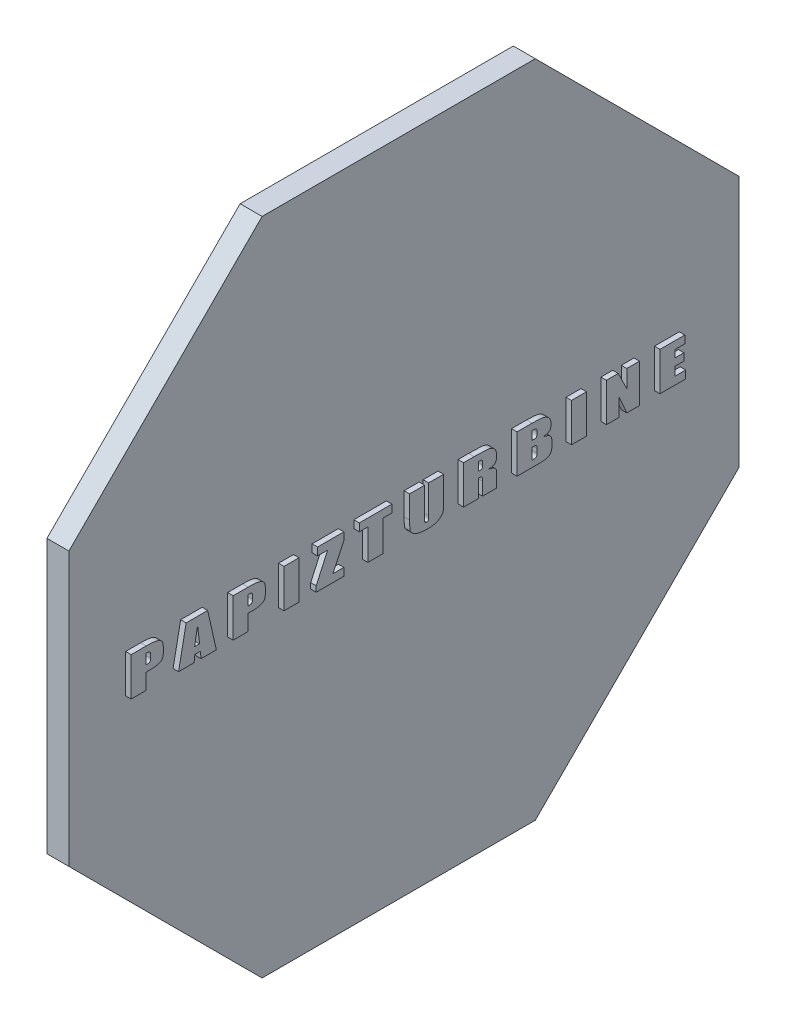
from build123d import *

# Parameters (mm, degrees)
BOSS_EXTRUDE1_DEPTH = 2
SKETCH2_R           = 28.115
BOSS_EXTRUDE2_DEPTH = 0.5
SKETCH3_W           = 1.35882353
SKETCH3_H           = 3.5
SKETCH3_W_2         = 1.358823529
BOSS_EXTRUDE3_DEPTH = 0.5


with BuildPart() as part:
    # Sketch1 → Boss-Extrude1 (new body)
    with BuildSketch(Plane(origin=(0, 0, 0), x_dir=(0, 0, -1), z_dir=(1, 0, 0))):
        Polygon((-30, 6.213203436), (-12.426406871, 23.786796564), (12.426406871, 23.786796564), (30.963363929, 5.249839506), (30.963363929, -17.676246377), (12.426406871, -36.213203436), (-12.426406871, -36.213203436), (-30, -18.639610307), align=None)
    extrude(amount=BOSS_EXTRUDE1_DEPTH)

    # Sketch2 → Boss-Extrude2 (add)
    with BuildSketch(Plane.ZY):
        with Locations((0, -6.213203436)):
            Circle(SKETCH2_R)
    extrude(amount=BOSS_EXTRUDE2_DEPTH)

    # Sketch3 → Boss-Extrude3 (add)
    with BuildSketch(Plane(origin=(2, 0, 0), x_dir=(0, 0, -1), z_dir=(1, 0, 0))):
        with BuildLine():
            Line((-24.836470588, -4.281409822), (-23.469926471, -4.281409822))
            add(Edge.make_bspline(
                [(-23.469926471, -4.281409822), (-23.425101442, -4.281405393), (-23.338011949, -4.281396789), (-23.211476018, -4.284987067), (-23.092873966, -4.289464045), (-22.982137851, -4.294805407), (-22.879383931, -4.303210882), (-22.784814533, -4.313601578), (-22.698266469, -4.324838982), (-22.619369548, -4.338583734), (-22.546378684, -4.353432135), (-22.478479043, -4.369905831), (-22.415417836, -4.388581779), (-22.357116435, -4.408765293), (-22.303126878, -4.429504237), (-22.253920983, -4.45279967), (-22.209493707, -4.477885134), (-22.157208479, -4.512451241), (-22.099608589, -4.559239418), (-22.042698667, -4.623017809), (-21.996269664, -4.691761253), (-21.96936758, -4.755374502), (-21.953320666, -4.810375007), (-21.942472988, -4.856996042), (-21.932611986, -4.908865982), (-21.92608072, -4.966318462), (-21.920246186, -5.028735747), (-21.915694745, -5.096304272), (-21.913139224, -5.16925708), (-21.913008844, -5.219673694), (-21.912941176, -5.245839969)],
                knots=[0, 0, 0, 0, 0.000134468, 0.000261256, 0.000379724, 0.000490537, 0.000593817, 0.000688953, 0.00077594, 0.000855587, 0.00092915, 0.00099937, 0.001065124, 0.001126367, 0.001184432, 0.001238538, 0.001289532, 0.001337355, 0.001426488, 0.001511229, 0.001592956, 0.001674226, 0.001717179, 0.001764776, 0.001817776, 0.001875473, 0.001938149, 0.002005854, 0.002078602, 0.002157097, 0.002157097, 0.002157097, 0.002157097], degree=3))
            Line((-21.912941176, -5.245839969), (-21.912941176, -5.546299528))
            add(Edge.make_bspline(
                [(-21.912941176, -5.546299528), (-21.91302739, -5.572906859), (-21.913193743, -5.624246763), (-21.918985118, -5.69845728), (-21.92577172, -5.76715505), (-21.938112938, -5.830109998), (-21.951220936, -5.887932251), (-21.969926294, -5.93967271), (-21.989849404, -5.986561937), (-22.015012001, -6.027750729), (-22.04395761, -6.065457537), (-22.078190443, -6.100119104), (-22.117916574, -6.132276841), (-22.16243981, -6.162836571), (-22.212960106, -6.190139942), (-22.268417051, -6.215856149), (-22.329106444, -6.239818328), (-22.39536495, -6.260853617), (-22.466991537, -6.27919021), (-22.543667057, -6.2964037), (-22.626078053, -6.309166585), (-22.713506187, -6.321283532), (-22.806312271, -6.329015634), (-22.904099073, -6.335693972), (-23.007304213, -6.339527169), (-23.077889228, -6.339993752), (-23.114136029, -6.340233351)],
                knots=[0, 0, 0, 0, 7.979e-05, 0.000153958, 0.000223231, 0.000286705, 0.000346314, 0.000400846, 0.000451539, 0.000498874, 0.000545202, 0.000593883, 0.000644629, 0.000698342, 0.000755647, 0.00081667, 0.000881664, 0.000951251, 0.001025063, 0.001103432, 0.001186886, 0.001275149, 0.001368173, 0.001466178, 0.001569192, 0.001677931, 0.001677931, 0.001677931, 0.001677931], degree=3))
            Line((-23.114136029, -6.340233351), (-23.477647059, -6.340233351))
            Line((-23.477647059, -6.340233351), (-23.477647059, -7.781409822))
            Line((-23.477647059, -7.781409822), (-24.836470588, -7.781409822))
            Line((-24.836470588, -7.781409822), (-24.836470588, -4.281409822))
        make_face()
        with BuildLine():
            Line((-23.477647059, -4.85788041), (-23.477647059, -5.761832616))
            add(Edge.make_bspline(
                [(-23.477647059, -5.761832616), (-23.460491144, -5.762309262), (-23.428755679, -5.763190974), (-23.397010488, -5.763582769), (-23.382426471, -5.763762763)],
                knots=[0, 0, 0, 0, 5.1487e-05, 9.5241e-05, 9.5241e-05, 9.5241e-05, 9.5241e-05], degree=3))
            add(Edge.make_bspline(
                [(-23.382426471, -5.763762763), (-23.35494615, -5.763112615), (-23.304196772, -5.761911953), (-23.234459263, -5.751248359), (-23.178586037, -5.731373566), (-23.140367871, -5.708302022), (-23.11837518, -5.68320143), (-23.10427052, -5.661022586), (-23.091638793, -5.634826623), (-23.082767713, -5.604065594), (-23.074550784, -5.569362909), (-23.070002748, -5.530307722), (-23.06665438, -5.487166716), (-23.066146745, -5.457091997), (-23.065882353, -5.441428204)],
                knots=[0, 0, 0, 0, 8.2443e-05, 0.000152253, 0.000210464, 0.000259715, 0.000283865, 0.00030992, 0.000338411, 0.000370766, 0.000405729, 0.000445311, 0.000488538, 0.000535522, 0.000535522, 0.000535522, 0.000535522], degree=3))
            Line((-23.065882353, -5.441428204), (-23.065882353, -5.149332616))
            add(Edge.make_bspline(
                [(-23.065882353, -5.149332616), (-23.066075228, -5.134735201), (-23.066441884, -5.106985541), (-23.070628434, -5.067495747), (-23.075898477, -5.031588385), (-23.084925008, -4.999986474), (-23.095793146, -4.971819213), (-23.110116254, -4.948256891), (-23.125969469, -4.927663129), (-23.14576161, -4.911671626), (-23.169187256, -4.898358651), (-23.197808987, -4.887956844), (-23.231278123, -4.878206105), (-23.270257409, -4.87061682), (-23.314566818, -4.865200579), (-23.36411428, -4.860563774), (-23.419073584, -4.85807302), (-23.457485494, -4.857946708), (-23.477647059, -4.85788041)],
                knots=[0, 0, 0, 0, 4.3769e-05, 8.3205e-05, 0.000119061, 0.000152468, 0.000181619, 0.000209315, 0.000234937, 0.000259156, 0.000285092, 0.00031544, 0.00035026, 0.000389627, 0.000434397, 0.000484141, 0.000538889, 0.000599371, 0.000599371, 0.000599371, 0.000599371], degree=3))
        make_face(mode=Mode.SUBTRACT)
        Polygon((-17.879705882, -4.281409822), (-17.087058824, -7.781409822), (-18.476764706, -7.781409822), (-18.548180147, -7.163762763), (-19.043584559, -7.163762763), (-19.115, -7.781409822), (-20.525294118, -7.781409822), (-19.835588235, -4.281409822), align=None)
        with BuildLine():
            add(Edge.make_bspline(
                [(-18.609301471, -6.546115704), (-18.615721023, -6.4929277), (-18.628897965, -6.383752608), (-18.64947351, -6.215613594), (-18.671709793, -6.038539558), (-18.693482531, -5.852457751), (-18.718918456, -5.657713412), (-18.742464881, -5.453786322), (-18.769400985, -5.241161877), (-18.786943241, -5.096369169), (-18.795882353, -5.022586292)],
                knots=[0, 0, 0, 0, 0.000160722, 0.000329902, 0.00050818, 0.000696114, 0.000891948, 0.00109736, 0.001311947, 0.001534914, 0.001534914, 0.001534914, 0.001534914], degree=3))
            add(Edge.make_bspline(
                [(-18.795882353, -5.022586292), (-18.810596459, -5.106669742), (-18.838979655, -5.268864927), (-18.881360925, -5.503095295), (-18.918852638, -5.720073536), (-18.954392164, -5.919242747), (-18.986680329, -6.100869863), (-19.015325743, -6.265025068), (-19.042069926, -6.411360595), (-19.058012876, -6.503212995), (-19.065459559, -6.546115704)],
                knots=[0, 0, 0, 0, 0.000256083, 0.000493979, 0.000714097, 0.00091666, 0.001100924, 0.001267521, 0.001416565, 0.001547197, 0.001547197, 0.001547197, 0.001547197], degree=3))
            Line((-19.065459559, -6.546115704), (-18.609301471, -6.546115704))
        make_face(mode=Mode.SUBTRACT)
        with BuildLine():
            Line((-15.555294118, -4.281409822), (-14.18875, -4.281409822))
            add(Edge.make_bspline(
                [(-14.18875, -4.281409822), (-14.143924972, -4.281405393), (-14.056835478, -4.281396789), (-13.930299548, -4.284987067), (-13.811697495, -4.289464045), (-13.700961381, -4.294805407), (-13.59820746, -4.303210882), (-13.503638062, -4.313601578), (-13.417089999, -4.324838982), (-13.338193077, -4.338583734), (-13.265202213, -4.353432135), (-13.197302572, -4.369905831), (-13.134241365, -4.388581779), (-13.075939964, -4.408765293), (-13.021950407, -4.429504237), (-12.972744512, -4.45279967), (-12.928317237, -4.477885134), (-12.876032008, -4.512451241), (-12.818432118, -4.559239418), (-12.761522196, -4.623017809), (-12.715093193, -4.691761253), (-12.68819111, -4.755374502), (-12.672144195, -4.810375007), (-12.661296517, -4.856996042), (-12.651435515, -4.908865982), (-12.644904249, -4.966318462), (-12.639069715, -5.028735747), (-12.634518274, -5.096304272), (-12.631962754, -5.16925708), (-12.631832373, -5.219673694), (-12.631764706, -5.245839969)],
                knots=[0, 0, 0, 0, 0.000134468, 0.000261256, 0.000379724, 0.000490537, 0.000593817, 0.000688953, 0.00077594, 0.000855587, 0.00092915, 0.00099937, 0.001065124, 0.001126367, 0.001184432, 0.001238538, 0.001289532, 0.001337355, 0.001426488, 0.001511229, 0.001592956, 0.001674226, 0.001717179, 0.001764776, 0.001817776, 0.001875473, 0.001938149, 0.002005854, 0.002078602, 0.002157097, 0.002157097, 0.002157097, 0.002157097], degree=3))
            Line((-12.631764706, -5.245839969), (-12.631764706, -5.546299528))
            add(Edge.make_bspline(
                [(-12.631764706, -5.546299528), (-12.63185092, -5.572906859), (-12.632017272, -5.624246763), (-12.637808647, -5.69845728), (-12.64459525, -5.76715505), (-12.656936467, -5.830109998), (-12.670044466, -5.887932251), (-12.688749823, -5.93967271), (-12.708672933, -5.986561937), (-12.73383553, -6.027750729), (-12.762781139, -6.065457537), (-12.797013972, -6.100119104), (-12.836740104, -6.132276841), (-12.881263339, -6.162836571), (-12.931783636, -6.190139942), (-12.987240581, -6.215856149), (-13.047929974, -6.239818328), (-13.114188479, -6.260853617), (-13.185815066, -6.27919021), (-13.262490587, -6.2964037), (-13.344901583, -6.309166585), (-13.432329717, -6.321283532), (-13.525135801, -6.329015634), (-13.622922603, -6.335693972), (-13.726127743, -6.339527169), (-13.796712758, -6.339993752), (-13.832959559, -6.340233351)],
                knots=[0, 0, 0, 0, 7.979e-05, 0.000153958, 0.000223231, 0.000286705, 0.000346314, 0.000400846, 0.000451539, 0.000498874, 0.000545202, 0.000593883, 0.000644629, 0.000698342, 0.000755647, 0.00081667, 0.000881664, 0.000951251, 0.001025063, 0.001103432, 0.001186886, 0.001275149, 0.001368173, 0.001466178, 0.001569192, 0.001677931, 0.001677931, 0.001677931, 0.001677931], degree=3))
            Line((-13.832959559, -6.340233351), (-14.196470588, -6.340233351))
            Line((-14.196470588, -6.340233351), (-14.196470588, -7.781409822))
            Line((-14.196470588, -7.781409822), (-15.555294118, -7.781409822))
            Line((-15.555294118, -7.781409822), (-15.555294118, -4.281409822))
        make_face()
        with BuildLine():
            Line((-14.196470588, -4.85788041), (-14.196470588, -5.761832616))
            add(Edge.make_bspline(
                [(-14.196470588, -5.761832616), (-14.179314673, -5.762309262), (-14.147579208, -5.763190974), (-14.115834018, -5.763582769), (-14.10125, -5.763762763)],
                knots=[0, 0, 0, 0, 5.1487e-05, 9.5241e-05, 9.5241e-05, 9.5241e-05, 9.5241e-05], degree=3))
            add(Edge.make_bspline(
                [(-14.10125, -5.763762763), (-14.073769679, -5.763112615), (-14.023020302, -5.761911953), (-13.953282792, -5.751248359), (-13.897409567, -5.731373566), (-13.859191401, -5.708302022), (-13.837198709, -5.68320143), (-13.82309405, -5.661022586), (-13.810462322, -5.634826623), (-13.801591243, -5.604065594), (-13.793374314, -5.569362909), (-13.788826278, -5.530307722), (-13.78547791, -5.487166716), (-13.784970274, -5.457091997), (-13.784705882, -5.441428204)],
                knots=[0, 0, 0, 0, 8.2443e-05, 0.000152253, 0.000210464, 0.000259715, 0.000283865, 0.00030992, 0.000338411, 0.000370766, 0.000405729, 0.000445311, 0.000488538, 0.000535522, 0.000535522, 0.000535522, 0.000535522], degree=3))
            Line((-13.784705882, -5.441428204), (-13.784705882, -5.149332616))
            add(Edge.make_bspline(
                [(-13.784705882, -5.149332616), (-13.784898758, -5.134735201), (-13.785265413, -5.106985541), (-13.789451964, -5.067495747), (-13.794722006, -5.031588385), (-13.803748538, -4.999986474), (-13.814616675, -4.971819213), (-13.828939784, -4.948256891), (-13.844792998, -4.927663129), (-13.864585139, -4.911671626), (-13.888010785, -4.898358651), (-13.916632516, -4.887956844), (-13.950101652, -4.878206105), (-13.989080939, -4.87061682), (-14.033390347, -4.865200579), (-14.08293781, -4.860563774), (-14.137897113, -4.85807302), (-14.176309023, -4.857946708), (-14.196470588, -4.85788041)],
                knots=[0, 0, 0, 0, 4.3769e-05, 8.3205e-05, 0.000119061, 0.000152468, 0.000181619, 0.000209315, 0.000234937, 0.000259156, 0.000285092, 0.00031544, 0.00035026, 0.000389627, 0.000434397, 0.000484141, 0.000538889, 0.000599371, 0.000599371, 0.000599371, 0.000599371], degree=3))
        make_face(mode=Mode.SUBTRACT)
        with Locations((-10.255882353, -6.031409822)):
            Rectangle(SKETCH3_W, SKETCH3_H)
        Polygon((-5.491764706, -4.281409822), (-5.491764706, -4.981409822), (-6.490294118, -7.081409822), (-5.491764706, -7.081409822), (-5.491764706, -7.781409822), (-8.003529412, -7.781409822), (-8.003529412, -7.273781145), (-6.963180147, -4.981409822), (-7.88, -4.981409822), (-7.88, -4.281409822), align=None)
        Polygon((-1.118823529, -4.281409822), (-1.118823529, -4.981409822), (-1.942352941, -4.981409822), (-1.942352941, -7.781409822), (-3.301176471, -7.781409822), (-3.301176471, -4.981409822), (-4.083529412, -4.981409822), (-4.083529412, -4.281409822), align=None)
        with BuildLine():
            Line((3.583529412, -4.281409822), (3.583529412, -6.626538498))
            add(Edge.make_bspline(
                [(3.583529412, -6.626538498), (3.583444896, -6.658495339), (3.583282655, -6.719841698), (3.580979182, -6.808190179), (3.579066078, -6.889315597), (3.574033598, -6.963050416), (3.569600084, -7.029442718), (3.562119431, -7.088154793), (3.554667581, -7.139718162), (3.543207438, -7.199851003), (3.517069697, -7.271107603), (3.469000461, -7.35472259), (3.400442606, -7.437730804), (3.316579685, -7.522378625), (3.214714995, -7.601683323), (3.096326103, -7.67103906), (2.963644254, -7.731189945), (2.815741938, -7.779513128), (2.653543522, -7.816991731), (2.477703032, -7.844581218), (2.287831123, -7.860354737), (2.156751246, -7.862600946), (2.088952206, -7.863762763)],
                knots=[0, 0, 0, 0, 9.5866e-05, 0.000184031, 0.000265138, 0.000339264, 0.000405732, 0.000464706, 0.000516752, 0.00056205, 0.000648131, 0.000742936, 0.000850047, 0.000970151, 0.00109988, 0.00123604, 0.001380871, 0.001536107, 0.001701998, 0.001879807, 0.002069644, 0.002273035, 0.002273035, 0.002273035, 0.002273035], degree=3))
            add(Edge.make_bspline(
                [(2.088952206, -7.863762763), (2.013852223, -7.862569659), (1.867680694, -7.860247452), (1.655190061, -7.84109391), (1.456182525, -7.808118444), (1.299728224, -7.770856131), (1.183127985, -7.734246472), (1.102445904, -7.705213391), (1.027315976, -7.674743006), (0.958072913, -7.641607067), (0.894012612, -7.60703853), (0.835825455, -7.56994187), (0.783120175, -7.531060615), (0.721713962, -7.478132918), (0.657055002, -7.408420739), (0.594397993, -7.321028516), (0.550195457, -7.230607891), (0.528519052, -7.150557748), (0.518852143, -7.079848527), (0.512592358, -7.014374646), (0.507718995, -6.936041084), (0.503314631, -6.845098697), (0.499358181, -6.741300751), (0.496902832, -6.624833724), (0.495801781, -6.495505104), (0.4954686, -6.405000663), (0.495294118, -6.357604675)],
                knots=[0, 0, 0, 0, 0.000225276, 0.000438467, 0.000639327, 0.000830016, 0.000920365, 0.001005841, 0.001087205, 0.001163467, 0.001236021, 0.001305449, 0.001370304, 0.001432342, 0.001548424, 0.001654631, 0.001753908, 0.001848652, 0.001901971, 0.00196791, 0.00204593, 0.002137401, 0.002241057, 0.002357538, 0.002486864, 0.002629053, 0.002629053, 0.002629053, 0.002629053], degree=3))
            Line((0.495294118, -6.357604675), (0.495294118, -4.281409822))
            Line((0.495294118, -4.281409822), (1.854117647, -4.281409822))
            Line((1.854117647, -4.281409822), (1.854117647, -6.927641439))
            add(Edge.make_bspline(
                [(1.854117647, -6.927641439), (1.854314438, -6.946084027), (1.854687474, -6.981043617), (1.85549355, -7.031067876), (1.858958924, -7.075667569), (1.862833915, -7.115347124), (1.866942083, -7.149785633), (1.872678874, -7.179054811), (1.879528475, -7.203082043), (1.890371991, -7.228074986), (1.910160784, -7.252985974), (1.94321731, -7.27367556), (1.98478133, -7.285669077), (2.015307119, -7.28672528), (2.031691176, -7.287292175)],
                knots=[0, 0, 0, 0, 5.5335e-05, 0.000104892, 0.000150043, 0.000189479, 0.000224512, 0.000254038, 0.000278873, 0.00029932, 0.000335493, 0.000372256, 0.000414592, 0.000463641, 0.000463641, 0.000463641, 0.000463641], degree=3))
            add(Edge.make_bspline(
                [(2.031691176, -7.287292175), (2.050446266, -7.286604599), (2.084905344, -7.285341304), (2.131351816, -7.272156168), (2.167476784, -7.249569296), (2.187979714, -7.221922144), (2.198817803, -7.194283566), (2.205318297, -7.167149125), (2.21209384, -7.134408633), (2.21599329, -7.095388532), (2.219838648, -7.050570783), (2.223351424, -6.999750119), (2.22412946, -6.942869368), (2.224506989, -6.902977525), (2.224705882, -6.881961292)],
                knots=[0, 0, 0, 0, 5.6155e-05, 0.000103175, 0.000143148, 0.00018175, 0.000203973, 0.000231906, 0.000265344, 0.000304208, 0.00034941, 0.000400339, 0.000456971, 0.000520026, 0.000520026, 0.000520026, 0.000520026], degree=3))
            Line((2.224705882, -6.881961292), (2.224705882, -4.281409822))
            Line((2.224705882, -4.281409822), (3.583529412, -4.281409822))
        make_face()
        with BuildLine():
            Line((5.403529412, -4.281409822), (6.356378676, -4.281409822))
            add(Edge.make_bspline(
                [(6.356378676, -4.281409822), (6.432513175, -4.281461402), (6.578567719, -4.281560353), (6.787887235, -4.284279574), (6.978119287, -4.288103724), (7.148864545, -4.292864007), (7.300496123, -4.300028844), (7.432850026, -4.308214294), (7.546182803, -4.317457882), (7.642863999, -4.328916566), (7.727970102, -4.34403796), (7.806637236, -4.363348595), (7.881596189, -4.387018374), (7.95268233, -4.415940231), (8.019417773, -4.450402836), (8.083046745, -4.487966439), (8.14186338, -4.531800339), (8.197368108, -4.579740027), (8.248482262, -4.633811691), (8.291403147, -4.696442713), (8.32855889, -4.765750364), (8.357861078, -4.843078211), (8.380874753, -4.927570308), (8.397354625, -5.019495189), (8.407916597, -5.118847163), (8.408901866, -5.187692532), (8.409411765, -5.223321586)],
                knots=[0, 0, 0, 0, 0.000228402, 0.00043816, 0.000627997, 0.000799214, 0.000950575, 0.001083375, 0.001197021, 0.001291666, 0.001375338, 0.001456169, 0.001534506, 0.001610971, 0.00168607, 0.001759667, 0.001832372, 0.001905788, 0.001979539, 0.002054858, 0.002132859, 0.002214943, 0.00230235, 0.002395229, 0.002494844, 0.002601693, 0.002601693, 0.002601693, 0.002601693], degree=3))
            add(Edge.make_bspline(
                [(8.409411765, -5.223321586), (8.408922506, -5.25550616), (8.407985112, -5.317170098), (8.40079384, -5.405676555), (8.389804423, -5.486000314), (8.37318376, -5.558225995), (8.351314626, -5.621924393), (8.325733937, -5.678202531), (8.295141827, -5.726469121), (8.257680996, -5.766330701), (8.213466073, -5.800162504), (8.161116833, -5.82936307), (8.099755332, -5.855111997), (8.029277045, -5.877329455), (7.949538563, -5.89653938), (7.860487306, -5.91147669), (7.762636881, -5.923965684), (7.69421926, -5.928618695), (7.658584559, -5.931042175)],
                knots=[0, 0, 0, 0, 9.6542e-05, 0.000184969, 0.000266221, 0.000339569, 0.000406916, 0.000467939, 0.000524688, 0.000577492, 0.000631156, 0.000691087, 0.000756813, 0.000830469, 0.00091255, 0.001002669, 0.001101224, 0.001208353, 0.001208353, 0.001208353, 0.001208353], degree=3))
            add(Edge.make_bspline(
                [(7.658584559, -5.931042175), (7.69099384, -5.936910654), (7.753161842, -5.948167665), (7.842151713, -5.966520821), (7.922757002, -5.986855176), (7.994667532, -6.00966), (8.058902787, -6.032188548), (8.114382659, -6.057610468), (8.162335352, -6.083188705), (8.212373753, -6.119912313), (8.26344277, -6.165033474), (8.313978567, -6.21840758), (8.351096415, -6.270008232), (8.374177961, -6.314006414), (8.38409685, -6.354346426), (8.391159613, -6.393844773), (8.396374887, -6.443972018), (8.401685835, -6.504433089), (8.405298047, -6.575250533), (8.40783934, -6.656330728), (8.408903699, -6.747920855), (8.409236155, -6.812475988), (8.409411765, -6.846575263)],
                knots=[0, 0, 0, 0, 9.8807e-05, 0.000189533, 0.000272549, 0.000348045, 0.00041582, 0.000476574, 0.000531004, 0.000578497, 0.000662384, 0.000735225, 0.000798424, 0.000852808, 0.000882772, 0.000922651, 0.000973168, 0.001033865, 0.001104742, 0.001185849, 0.001277218, 0.001379518, 0.001379518, 0.001379518, 0.001379518], degree=3))
            Line((8.409411765, -6.846575263), (8.409411765, -7.781409822))
            Line((8.409411765, -7.781409822), (7.132941176, -7.781409822))
            Line((7.132941176, -7.781409822), (7.132941176, -6.597586292))
            add(Edge.make_bspline(
                [(7.132941176, -6.597586292), (7.13296586, -6.574846971), (7.133012697, -6.53170077), (7.129413792, -6.470572367), (7.125205085, -6.41602125), (7.119053032, -6.368290382), (7.110834607, -6.327149951), (7.10063341, -6.293151093), (7.089459698, -6.265189576), (7.074732712, -6.243242983), (7.055409673, -6.226175234), (7.030707508, -6.213054239), (7.000953198, -6.20052069), (6.964734252, -6.191334348), (6.922524565, -6.184468725), (6.8743958, -6.179504724), (6.820299333, -6.176313459), (6.782302706, -6.175798069), (6.762352941, -6.175527469)],
                knots=[0, 0, 0, 0, 6.8202e-05, 0.000129407, 0.000183639, 0.00023232, 0.000273707, 0.000309326, 0.000338725, 0.000363709, 0.00038786, 0.000415232, 0.000447253, 0.000484552, 0.000526967, 0.000575494, 0.000629634, 0.000689482, 0.000689482, 0.000689482, 0.000689482], degree=3))
            Line((6.762352941, -6.175527469), (6.762352941, -7.781409822))
            Line((6.762352941, -7.781409822), (5.403529412, -7.781409822))
            Line((5.403529412, -7.781409822), (5.403529412, -4.281409822))
        make_face()
        with BuildLine():
            Line((6.762352941, -4.85788041), (6.762352941, -5.640233351))
            add(Edge.make_bspline(
                [(6.762352941, -5.640233351), (6.79411588, -5.639918735), (6.852627092, -5.639339172), (6.932698685, -5.630944882), (6.99763394, -5.618922909), (7.042867021, -5.603788668), (7.071140541, -5.584673447), (7.088163455, -5.564418103), (7.102034103, -5.538230937), (7.11346963, -5.506350954), (7.122270727, -5.468783007), (7.128498506, -5.425518022), (7.132323865, -5.376300573), (7.132727295, -5.341497154), (7.132941176, -5.323045851)],
                knots=[0, 0, 0, 0, 9.5255e-05, 0.000175472, 0.000241084, 0.00029342, 0.000316981, 0.000342522, 0.000371893, 0.000405479, 0.000443867, 0.000487451, 0.0005365, 0.000591846, 0.000591846, 0.000591846, 0.000591846], degree=3))
            Line((7.132941176, -5.323045851), (7.132941176, -5.129387763))
            add(Edge.make_bspline(
                [(7.132941176, -5.129387763), (7.132090731, -5.1037876), (7.130536385, -5.05699858), (7.116387476, -4.993355144), (7.09139002, -4.943320325), (7.053626176, -4.906473237), (7.001542739, -4.884505561), (6.936574416, -4.868139278), (6.854785952, -4.859408493), (6.794964661, -4.85841954), (6.762352941, -4.85788041)],
                knots=[0, 0, 0, 0, 7.6735e-05, 0.000140248, 0.000194066, 0.000242298, 0.000294965, 0.000361442, 0.000443081, 0.000540928, 0.000540928, 0.000540928, 0.000540928], degree=3))
        make_face(mode=Mode.SUBTRACT)
        with BuildLine():
            Line((10.270588235, -4.281409822), (11.635845588, -4.281409822))
            add(Edge.make_bspline(
                [(11.635845588, -4.281409822), (11.68817467, -4.281759944), (11.789407299, -4.282437268), (11.936555012, -4.28470794), (12.073856898, -4.289639421), (12.201220147, -4.297733036), (12.31884844, -4.306220561), (12.426539757, -4.317823328), (12.524599831, -4.331273823), (12.613827364, -4.346423126), (12.696247077, -4.365527796), (12.773870475, -4.387447104), (12.847270129, -4.414938106), (12.916550005, -4.446215589), (12.982102511, -4.481963975), (13.043681266, -4.52138138), (13.100789329, -4.565919842), (13.154619286, -4.613838901), (13.203616869, -4.668228239), (13.245709171, -4.730514856), (13.280223854, -4.800932427), (13.309306956, -4.878451666), (13.331511441, -4.963655006), (13.347487982, -5.056401724), (13.357131832, -5.156848892), (13.358246639, -5.226516372), (13.358823529, -5.26256791)],
                knots=[0, 0, 0, 0, 0.000156991, 0.000303704, 0.000441484, 0.000569108, 0.000686549, 0.000795256, 0.000893979, 0.000983465, 0.00106665, 0.001147691, 0.001225253, 0.001301555, 0.001375547, 0.001449073, 0.001520625, 0.001592597, 0.001665048, 0.001739639, 0.001817326, 0.001899782, 0.001987643, 0.002081042, 0.002181873, 0.002290009, 0.002290009, 0.002290009, 0.002290009], degree=3))
            add(Edge.make_bspline(
                [(13.358823529, -5.26256791), (13.358234187, -5.286810883), (13.357100281, -5.33345485), (13.351155272, -5.400686871), (13.339281164, -5.461911887), (13.324235804, -5.517974307), (13.30381861, -5.568196586), (13.278329069, -5.612646366), (13.248760305, -5.651679342), (13.213550838, -5.685458952), (13.171578982, -5.715055925), (13.121401369, -5.741703578), (13.063054476, -5.767532931), (12.995309522, -5.789992193), (12.919643661, -5.813066492), (12.834318916, -5.832232345), (12.740652701, -5.851182352), (12.674956243, -5.86139543), (12.640808824, -5.866703939)],
                knots=[0, 0, 0, 0, 7.2748e-05, 0.000139968, 0.000202177, 0.000259622, 0.000313865, 0.0003643, 0.000412942, 0.000460265, 0.000510076, 0.000566507, 0.000630461, 0.000701268, 0.000780456, 0.000867694, 0.000963462, 0.001067119, 0.001067119, 0.001067119, 0.001067119], degree=3))
            add(Edge.make_bspline(
                [(12.640808824, -5.866703939), (12.678186946, -5.872796797), (12.750236931, -5.884541377), (12.853133328, -5.906956816), (12.946529528, -5.93263357), (13.030696837, -5.960765233), (13.105598971, -5.991905632), (13.170892427, -6.026883296), (13.227640978, -6.063748401), (13.274848, -6.105283106), (13.315199446, -6.150448047), (13.34856095, -6.201543809), (13.377766959, -6.257394138), (13.400726748, -6.3195798), (13.419414297, -6.386661874), (13.432049379, -6.459726156), (13.439807911, -6.538010151), (13.440711377, -6.592205511), (13.441176471, -6.620104675)],
                knots=[0, 0, 0, 0, 0.0001136, 0.000218976, 0.000315751, 0.000404051, 0.000485069, 0.000558755, 0.000626028, 0.000687581, 0.000746835, 0.000807149, 0.000870167, 0.00093553, 0.001005614, 0.001078813, 0.001157684, 0.001241364, 0.001241364, 0.001241364, 0.001241364], degree=3))
            Line((13.441176471, -6.620104675), (13.441176471, -6.948873057))
            add(Edge.make_bspline(
                [(13.441176471, -6.948873057), (13.440824346, -6.977834057), (13.440142816, -7.033887501), (13.434403148, -7.115096236), (13.424595685, -7.19041739), (13.412385187, -7.260300191), (13.394599547, -7.323970427), (13.374585699, -7.382512263), (13.349164696, -7.434615679), (13.320756812, -7.481947955), (13.287465318, -7.523867245), (13.250414803, -7.5624905), (13.208599618, -7.597004493), (13.162124394, -7.628163865), (13.111524117, -7.656567214), (13.055915262, -7.680619267), (12.99634219, -7.702288435), (12.929805656, -7.719911504), (12.852431522, -7.734819522), (12.759845084, -7.747313038), (12.650194688, -7.758141023), (12.522909861, -7.765912781), (12.378364802, -7.773097715), (12.216424108, -7.778232158), (12.037107395, -7.78038267), (11.911856887, -7.781056675), (11.846231618, -7.781409822)],
                knots=[0, 0, 0, 0, 8.6878e-05, 0.000168151, 0.000244043, 0.000314709, 0.000380731, 0.000442186, 0.000500026, 0.000554315, 0.000607471, 0.000660252, 0.00071462, 0.00076976, 0.000827939, 0.000888431, 0.000951315, 0.001017957, 0.001094673, 0.001187572, 0.001298133, 0.001425155, 0.001570089, 0.001732303, 0.001911182, 0.002108061, 0.002108061, 0.002108061, 0.002108061], degree=3))
            Line((11.846231618, -7.781409822), (10.270588235, -7.781409822))
            Line((10.270588235, -7.781409822), (10.270588235, -4.281409822))
        make_face()
        with BuildLine():
            Line((11.629411765, -4.85788041), (11.629411765, -5.640233351))
            add(Edge.make_bspline(
                [(11.629411765, -5.640233351), (11.655789897, -5.639764475), (11.701682156, -5.638948731), (11.747579359, -5.638495798), (11.767095588, -5.638303204)],
                knots=[0, 0, 0, 0, 7.9146e-05, 0.000137698, 0.000137698, 0.000137698, 0.000137698], degree=3))
            add(Edge.make_bspline(
                [(11.767095588, -5.638303204), (11.783396849, -5.637958556), (11.814303605, -5.637305113), (11.858367251, -5.635076056), (11.897799648, -5.630168965), (11.932480893, -5.622140133), (11.963159139, -5.613646268), (11.988991871, -5.60216796), (12.010064928, -5.588498127), (12.027696827, -5.572248467), (12.040823826, -5.549824292), (12.052099206, -5.521425037), (12.061667316, -5.485351608), (12.068844717, -5.441584613), (12.07539083, -5.390098358), (12.079602626, -5.33104069), (12.082199769, -5.26430787), (12.082299914, -5.217319608), (12.082352941, -5.192439233)],
                knots=[0, 0, 0, 0, 4.8914e-05, 9.274e-05, 0.000132322, 0.000167912, 0.000199464, 0.000227685, 0.000252311, 0.000274607, 0.000298886, 0.000329472, 0.000366151, 0.000410577, 0.000462448, 0.00052181, 0.000588128, 0.000662763, 0.000662763, 0.000662763, 0.000662763], degree=3))
            add(Edge.make_bspline(
                [(12.082352941, -5.192439233), (12.082100692, -5.166872224), (12.081634523, -5.119623049), (12.072448104, -5.055209462), (12.059628053, -5.002177867), (12.038110523, -4.961603895), (12.012937175, -4.930133501), (11.98404499, -4.90608641), (11.952034949, -4.887346296), (11.913602409, -4.875447356), (11.865322259, -4.868262343), (11.802159204, -4.862740985), (11.721665353, -4.859204136), (11.662013373, -4.858348203), (11.629411765, -4.85788041)],
                knots=[0, 0, 0, 0, 7.6606e-05, 0.000141571, 0.000194953, 0.000239272, 0.000278158, 0.000315145, 0.000351455, 0.000388688, 0.000435016, 0.000497692, 0.00057885, 0.000676663, 0.000676663, 0.000676663, 0.000676663], degree=3))
        make_face(mode=Mode.SUBTRACT)
        with BuildLine():
            Line((11.629411765, -6.175527469), (11.629411765, -7.204939233))
            add(Edge.make_bspline(
                [(11.629411765, -7.204939233), (11.652576338, -7.204175845), (11.696785547, -7.20271893), (11.759911195, -7.199162438), (11.816526445, -7.193186277), (11.866664486, -7.186604427), (11.910035125, -7.177517516), (11.946844219, -7.167354174), (11.977407479, -7.15630423), (12.002032159, -7.142374505), (12.021717441, -7.12443367), (12.038675083, -7.102414716), (12.051908324, -7.07439416), (12.063542737, -7.041934795), (12.071390205, -7.003993747), (12.078001946, -6.961295003), (12.081660805, -6.913334466), (12.082115687, -6.879607471), (12.082352941, -6.862016439)],
                knots=[0, 0, 0, 0, 6.9533e-05, 0.000132702, 0.000189615, 0.000240296, 0.000284333, 0.000322424, 0.000354804, 0.000381619, 0.000406678, 0.000434216, 0.000464427, 0.000499224, 0.000537466, 0.000580413, 0.000628821, 0.000681594, 0.000681594, 0.000681594, 0.000681594], degree=3))
            Line((12.082352941, -6.862016439), (12.082352941, -6.518450263))
            add(Edge.make_bspline(
                [(12.082352941, -6.518450263), (12.082058144, -6.499790581), (12.081498572, -6.464371622), (12.078642821, -6.414056664), (12.072590319, -6.369441074), (12.065685004, -6.330449295), (12.05496523, -6.297619696), (12.043253582, -6.270118529), (12.028347269, -6.248510968), (12.010471216, -6.231339409), (11.986606098, -6.220063755), (11.957567309, -6.208784696), (11.920651949, -6.200513672), (11.876663193, -6.192737267), (11.825310876, -6.186564507), (11.766519825, -6.181476672), (11.700434889, -6.177683722), (11.653864689, -6.176269857), (11.629411765, -6.175527469)],
                knots=[0, 0, 0, 0, 5.5989e-05, 0.000106276, 0.000151045, 0.000191044, 0.00022482, 0.000254478, 0.000280358, 0.000303123, 0.000327875, 0.000358824, 0.000396587, 0.000441013, 0.000492884, 0.000551657, 0.000618038, 0.000691429, 0.000691429, 0.000691429, 0.000691429], degree=3))
        make_face(mode=Mode.SUBTRACT)
        with Locations((15.899411765, -6.031409822)):
            Rectangle(SKETCH3_W_2, SKETCH3_H)
        Polygon((21.404705882, -4.281409822), (21.404705882, -7.781409822), (20.251764706, -7.781409822), (19.551764706, -6.190325263), (19.551764706, -7.781409822), (18.398823529, -7.781409822), (18.398823529, -4.281409822), (19.469411765, -4.281409822), (20.251764706, -5.857696586), (20.251764706, -4.281409822), align=None)
        Polygon((23.265882353, -4.281409822), (25.530588235, -4.281409822), (25.530588235, -4.981409822), (24.624705882, -4.981409822), (24.624705882, -5.640233351), (25.448235294, -5.640233351), (25.448235294, -6.29905688), (24.624705882, -6.29905688), (24.624705882, -7.081409822), (25.612941176, -7.081409822), (25.612941176, -7.781409822), (23.265882353, -7.781409822), align=None)
    extrude(amount=BOSS_EXTRUDE3_DEPTH)


solid = part.part
